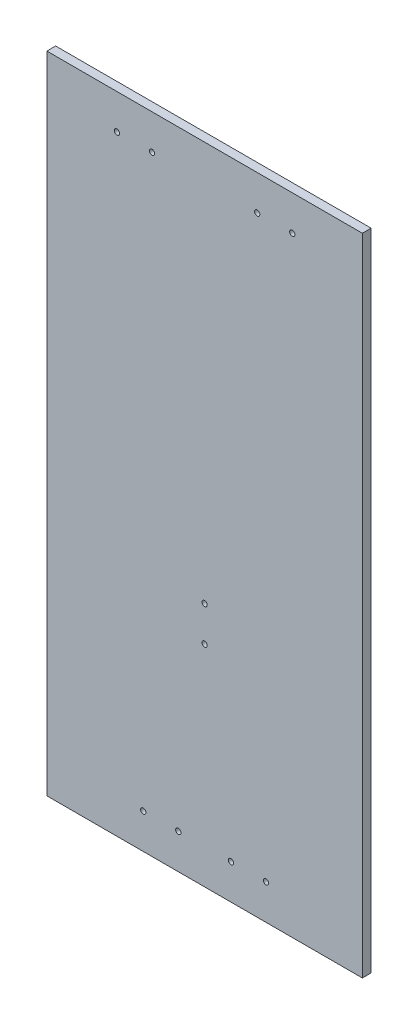
from build123d import *

# Parameters (mm, degrees)
CROQUIS1_W              = 180
CROQUIS1_H              = 368
CROQUIS1_R              = 1.5
SALIENTE_EXTRUIR1_DEPTH = 5


with BuildPart() as part:
    # Croquis1 → Saliente-Extruir1 (new body)
    with BuildSketch(Plane.XY):
        Rectangle(CROQUIS1_W, CROQUIS1_H)
        with Locations((15, -164)):
            Circle(CROQUIS1_R, mode=Mode.SUBTRACT)
        with Locations((35, -164)):
            Circle(CROQUIS1_R, mode=Mode.SUBTRACT)
        with Locations((-35, -164)):
            Circle(CROQUIS1_R, mode=Mode.SUBTRACT)
        with Locations((-15, -164)):
            Circle(CROQUIS1_R, mode=Mode.SUBTRACT)
        with Locations((30, 164)):
            Circle(CROQUIS1_R, mode=Mode.SUBTRACT)
        with Locations((50, 164)):
            Circle(CROQUIS1_R, mode=Mode.SUBTRACT)
        with Locations((-50, 164)):
            Circle(CROQUIS1_R, mode=Mode.SUBTRACT)
        with Locations((-30, 164)):
            Circle(CROQUIS1_R, mode=Mode.SUBTRACT)
        with Locations((0, -64)):
            Circle(CROQUIS1_R, mode=Mode.SUBTRACT)
        with Locations((0, -44)):
            Circle(CROQUIS1_R, mode=Mode.SUBTRACT)
    extrude(amount=SALIENTE_EXTRUIR1_DEPTH)


solid = part.part
